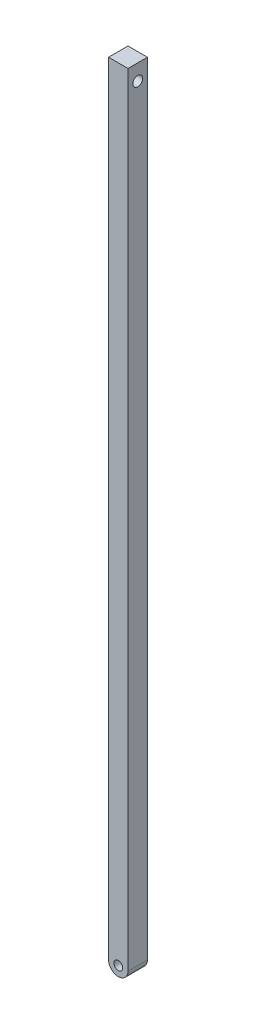
from build123d import *

# Parameters (mm, degrees)
SKETCH1_R           = 0.227761077
BOSS_EXTRUDE1_DEPTH = 1
SKETCH4_R           = 0.251968504
CUT_EXTRUDE1_DEPTH  = 10


with BuildPart() as part:
    # Sketch1 → Boss-Extrude1 (new body)
    with BuildSketch(Plane.XY):
        with BuildLine():
            Line((3.44382586, -27.356132879), (3.44382586, -66.756132879))
            ThreePointArc((3.44382586, -66.756132879), (3.94382586, -67.256132879), (4.44382586, -66.756132879))
            Line((4.44382586, -66.756132879), (4.44382586, -27.356132879))
            Line((4.44382586, -27.356132879), (4.44382586, -26.541134356))
            Line((4.44382586, -26.541134356), (3.44382586, -26.541134356))
            Line((3.44382586, -26.541134356), (3.44382586, -27.356132879))
        make_face()
        with Locations((3.94382586, -66.756132879)):
            Circle(SKETCH1_R, mode=Mode.SUBTRACT)
    extrude(amount=BOSS_EXTRUDE1_DEPTH)

    # Sketch4 → Cut-Extrude1 (cut)
    with BuildSketch(Plane(origin=(4.44382586, 0, 0), x_dir=(0, 0, -1), z_dir=(1, 0, 0))):
        with Locations((-0.5, -27.356132879)):
            Circle(SKETCH4_R)
    extrude(amount=-CUT_EXTRUDE1_DEPTH, mode=Mode.SUBTRACT)


solid = part.part
